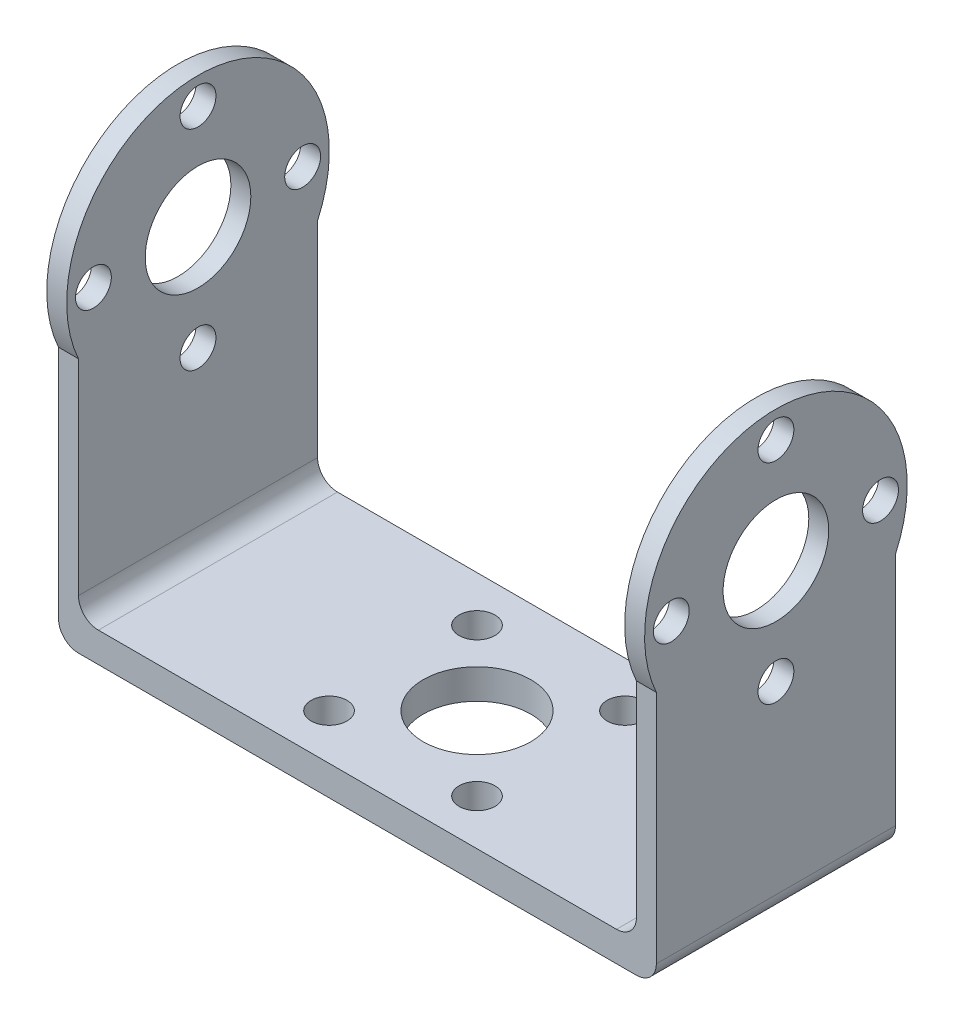
from build123d import *

# Parameters (mm, degrees)
CROQUIS1_W              = 60
CROQUIS1_H              = 24
SALIENTE_EXTRUIR1_DEPTH = 2
CROQUIS3_R              = 5.3
SALIENTE_EXTRUIR2_DEPTH = 2
CROQUIS5_R              = 1.8
CORTAR_EXTRUIR1_DEPTH   = 2
CROQUIS6_W              = 60
CROQUIS6_H              = 24
SALIENTE_EXTRUIR3_DEPTH = 1
CORTAR_EXTRUIR2_REACH   = 46.22
CROQUIS7_R              = 5.4
CROQUIS7_R_2            = 1.8
REDONDEO1_R             = 2


with BuildPart() as part:
    # Croquis1 → Saliente-Extruir1 (new body)
    with BuildSketch(Plane(origin=(0, 0, 0), x_dir=(1, 0, 0), z_dir=(0, 1, 0))):
        Rectangle(CROQUIS1_W, CROQUIS1_H)
    extrude(amount=SALIENTE_EXTRUIR1_DEPTH)

    # Croquis3 → Saliente-Extruir2 (add)
    with BuildSketch(Plane(origin=(30, 0, 0), x_dir=(0, 0, -1), z_dir=(1, 0, 0))):
        with BuildLine():
            Line((12, 2), (-12, 2))
            Line((-12, 2), (-12, 24.589091819))
            ThreePointArc((-12, 24.589091819), (0, 43.22), (12, 24.589091819))
            Line((12, 24.589091819), (12, 2))
        make_face()
        with Locations((0, 30.04)):
            Circle(CROQUIS3_R, mode=Mode.SUBTRACT)
    saliente_extruir2 = extrude(amount=-SALIENTE_EXTRUIR2_DEPTH)

    # Croquis5 → Cortar-Extruir1 (cut)
    with BuildSketch(Plane(origin=(30, 0, 0), x_dir=(0, 0, -1), z_dir=(1, 0, 0))):
        with Locations((0, 40.54)):
            Circle(CROQUIS5_R)
        with Locations((10.5, 30.04)):
            Circle(CROQUIS5_R)
        with Locations((0, 19.54)):
            Circle(CROQUIS5_R)
        with Locations((-10.5, 30.04)):
            Circle(CROQUIS5_R)
    cortar_extruir1 = extrude(amount=-CORTAR_EXTRUIR1_DEPTH, mode=Mode.SUBTRACT)

    # Simetría1: Saliente-Extruir2, Cortar-Extruir1 across plane
    add(saliente_extruir2.mirror(Plane(origin=(0, 0, 0), x_dir=(0, 0, 1), z_dir=(1, 0, 0))))
    add(cortar_extruir1.mirror(Plane(origin=(0, 0, 0), x_dir=(0, 0, 1), z_dir=(1, 0, 0))), mode=Mode.SUBTRACT)

    # Croquis6 → Saliente-Extruir3 (add)
    with BuildSketch(Plane.XZ):
        Rectangle(CROQUIS6_W, CROQUIS6_H)
    extrude(amount=SALIENTE_EXTRUIR3_DEPTH)

    # Croquis7 → Cortar-Extruir2 (cut, up to next)
    with BuildSketch(Plane.XZ.offset(1), mode=Mode.PRIVATE) as cortar_extruir2_sk1:
        Circle(CROQUIS7_R)
    cortar_extruir2_tool1 = extrude(cortar_extruir2_sk1.sketch, amount=-CORTAR_EXTRUIR2_REACH, mode=Mode.PRIVATE) & part.part
    add(cortar_extruir2_tool1.solids().sort_by_distance((0, -1, 0))[0], mode=Mode.SUBTRACT)
    # Croquis7 → Cortar-Extruir2 (cut, up to next)
    with BuildSketch(Plane.XZ.offset(1), mode=Mode.PRIVATE) as cortar_extruir2_sk2:
        with Locations((7.424621202, -7.424621202)):
            Circle(CROQUIS7_R_2)
    cortar_extruir2_tool2 = extrude(cortar_extruir2_sk2.sketch, amount=-CORTAR_EXTRUIR2_REACH, mode=Mode.PRIVATE) & part.part
    add(cortar_extruir2_tool2.solids().sort_by_distance((7.424621, -1, -7.424621))[0], mode=Mode.SUBTRACT)
    # Croquis7 → Cortar-Extruir2 (cut, up to next)
    with BuildSketch(Plane.XZ.offset(1), mode=Mode.PRIVATE) as cortar_extruir2_sk3:
        with Locations((-7.423621202, -7.423621202)):
            Circle(CROQUIS7_R_2)
    cortar_extruir2_tool3 = extrude(cortar_extruir2_sk3.sketch, amount=-CORTAR_EXTRUIR2_REACH, mode=Mode.PRIVATE) & part.part
    add(cortar_extruir2_tool3.solids().sort_by_distance((-7.423621, -1, -7.423621))[0], mode=Mode.SUBTRACT)
    # Croquis7 → Cortar-Extruir2 (cut, up to next)
    with BuildSketch(Plane.XZ.offset(1), mode=Mode.PRIVATE) as cortar_extruir2_sk4:
        with Locations((-7.422621202, 7.424621202)):
            Circle(CROQUIS7_R_2)
    cortar_extruir2_tool4 = extrude(cortar_extruir2_sk4.sketch, amount=-CORTAR_EXTRUIR2_REACH, mode=Mode.PRIVATE) & part.part
    add(cortar_extruir2_tool4.solids().sort_by_distance((-7.422621, -1, 7.424621))[0], mode=Mode.SUBTRACT)
    # Croquis7 → Cortar-Extruir2 (cut, up to next)
    with BuildSketch(Plane.XZ.offset(1), mode=Mode.PRIVATE) as cortar_extruir2_sk5:
        with Locations((7.425621202, 7.423621202)):
            Circle(CROQUIS7_R_2)
    cortar_extruir2_tool5 = extrude(cortar_extruir2_sk5.sketch, amount=-CORTAR_EXTRUIR2_REACH, mode=Mode.PRIVATE) & part.part
    add(cortar_extruir2_tool5.solids().sort_by_distance((7.425621, -1, 7.423621))[0], mode=Mode.SUBTRACT)

    # Redondeo1
    redondeo1_edges = [part.edges().sort_by_distance(p)[0] for p in [
        (-28, 2, 0),
        (28, 2, 0),
        (-30, -1, 0),
        (30, -1, 0),
    ]]
    fillet(redondeo1_edges, radius=REDONDEO1_R)


solid = part.part
